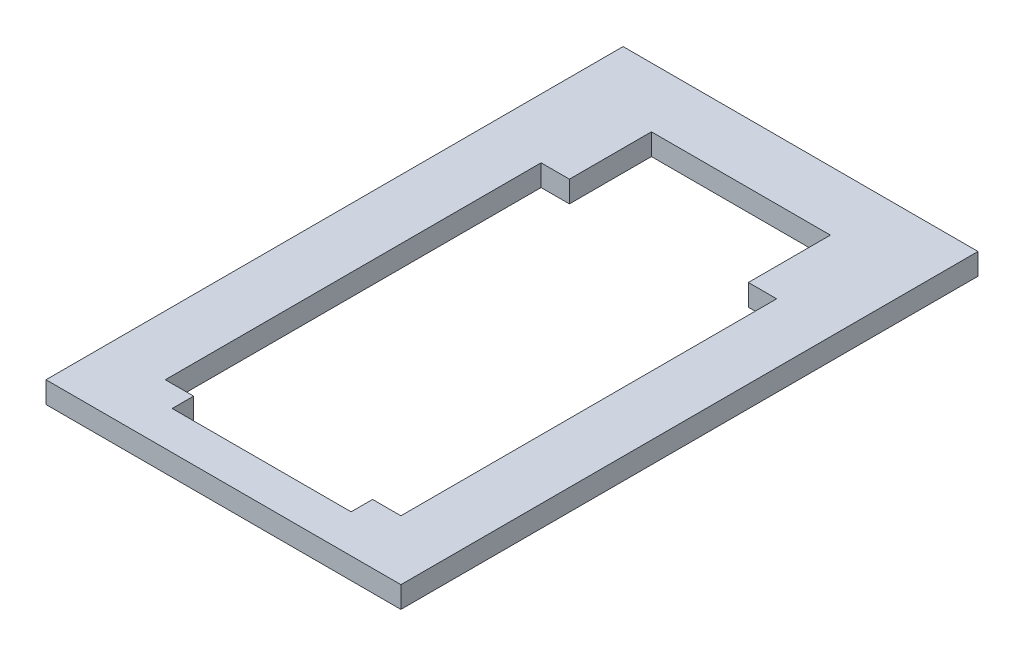
from build123d import *

# Parameters (mm, degrees)
SKETCH1_W           = 75.565
SKETCH1_H           = 105.41
SKETCH1_W_2         = 50.165
SKETCH1_H_2         = 80.01
BOSS_EXTRUDE1_DEPTH = 4.572
SKETCH2_W           = 38.1
SKETCH2_H           = 4.572
SKETCH2_H_2         = 8.128
CUT_EXTRUDE1_DEPTH  = 5.572
SKETCH3_W           = 38.1
SKETCH3_H           = 4.572
CUT_EXTRUDE2_DEPTH  = 5.572
SKETCH4_W           = 18.7325
SKETCH4_H           = 4.7625
BOSS_EXTRUDE2_DEPTH = 4.572


with BuildPart() as part:
    # Sketch1 → Boss-Extrude1 (new body)
    with BuildSketch(Plane(origin=(0, 0, 0), x_dir=(1, 0, 0), z_dir=(0, 1, 0))):
        Rectangle(SKETCH1_W, SKETCH1_H)
        Rectangle(SKETCH1_W_2, SKETCH1_H_2, mode=Mode.SUBTRACT)
    extrude(amount=BOSS_EXTRUDE1_DEPTH)

    # Sketch2 → Cut-Extrude1 (cut, through all)
    with BuildSketch(Plane(origin=(0, 4.572, 0), x_dir=(1, 0, 0), z_dir=(0, 1, 0))):
        with Locations((0, -42.291)):
            Rectangle(SKETCH2_W, SKETCH2_H)
        with Locations((0, 44.069)):
            Rectangle(SKETCH2_W, SKETCH2_H_2)
    extrude(amount=-CUT_EXTRUDE1_DEPTH, mode=Mode.SUBTRACT)

    # Sketch3 → Cut-Extrude2 (cut, through all)
    with BuildSketch(Plane(origin=(0, 4.572, 0), x_dir=(1, 0, 0), z_dir=(0, 1, 0))):
        with Locations((0, 50.419)):
            Rectangle(SKETCH3_W, SKETCH3_H)
    extrude(amount=-CUT_EXTRUDE2_DEPTH, mode=Mode.SUBTRACT)

    # Sketch4 → Boss-Extrude2 (add)
    with BuildSketch(Plane(origin=(0, 4.572, 0), x_dir=(1, 0, 0), z_dir=(0, 1, 0))):
        Polygon((-37.7825, 57.4675), (-19.05, 57.4675), (19.05, 57.4675), (37.7825, 57.4675), (37.7825, 70.1675), (-37.7825, 70.1675), align=None)
        with Locations((-28.41625, 55.08625)):
            Rectangle(SKETCH4_W, SKETCH4_H)
        with Locations((28.41625, 55.08625)):
            Rectangle(SKETCH4_W, SKETCH4_H)
    extrude(amount=-BOSS_EXTRUDE2_DEPTH)


solid = part.part
